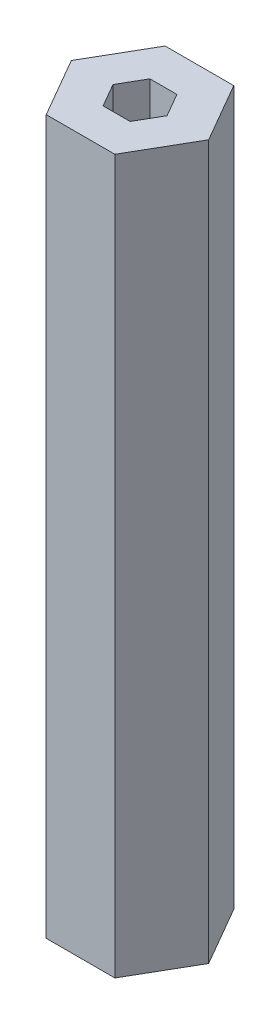
from build123d import *

# Parameters (mm, degrees)
BOSS_EXTRUDE1_DEPTH = 76.2


with BuildPart() as part:
    # Sketch1 → Boss-Extrude1 (new body)
    with BuildSketch(Plane(origin=(0, 0, 0), x_dir=(1, 0, 0), z_dir=(0, 1, 0))):
        Polygon((7.332348419, 0), (3.666174209, 6.35), (-3.666174209, 6.35), (-7.332348419, 0), (-3.666174209, -6.35), (3.666174209, -6.35), align=None)
        Polygon((2.886751346, 0), (1.443375673, 2.5), (-1.443375673, 2.5), (-2.886751346, 0), (-1.443375673, -2.5), (1.443375673, -2.5), align=None, mode=Mode.SUBTRACT)
    extrude(amount=BOSS_EXTRUDE1_DEPTH)


solid = part.part
